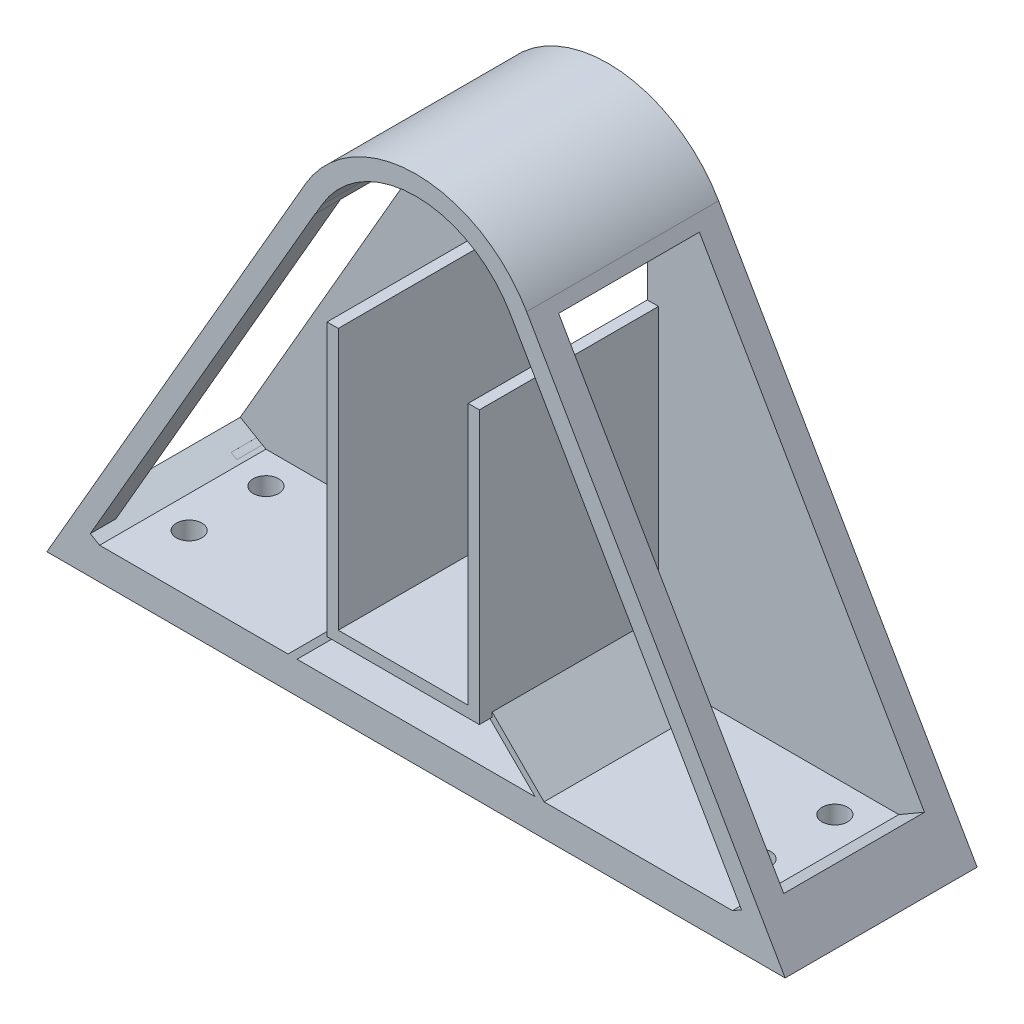
from build123d import *

# Parameters (mm, degrees)
SKETCH2_W                 = 200
SKETCH2_H                 = 200
BOSS_EXTRUDE2_DEPTH       = 60
BOSS_EXTRUDE3_START       = -38
BOSS_EXTRUDE3_DEPTH       = 41
SKETCH5_W                 = 180
SKETCH5_H                 = 180
CUT_EXTRUDE2_DEPTH        = 50
BOSS_EXTRUDE4_START       = -51.2
BOSS_EXTRUDE4_DEPTH       = 30
CUT_EXTRUDE3_DEPTH        = 35
SKETCH9_R                 = 5
CUT_EXTRUDE4_DEPTH        = 10
CUT_EXTRUDE6_DEPTH        = 26
SKETCH11_W                = 120
SKETCH11_H                = 10
CUT_EXTRUDE7_DEPTH        = 26
SKETCH12_W                = 180
SKETCH12_H                = 50
CUT_EXTRUDE8_DEPTH        = 200
SKETCH13_W                = 180
SKETCH13_H                = 50
CUT_EXTRUDE9_DEPTH        = 200
SKETCH15_W                = 19.8
SKETCH15_H                = 40.6
SKETCH15_R                = 4.016151872
CUT_EXTRUDE11_DEPTH       = 10
BOSS_EXTRUDE5_DEPTH       = 26
SKETCH20_W                = 19.8
SKETCH20_H                = 7
CUT_EXTRUDE14_DEPTH       = 8.2
SKETCH22_W                = 22
SKETCH22_H                = 68.38628635
SKETCH22_W_2              = 33
SKETCH22_H_2              = 70.357034464
CUT_EXTRUDE16_DEPTH       = 6
CUT_EXTRUDE17_DEPTH       = 150
SKETCH24_W                = 190
SKETCH24_H                = 55
CUT_EXTRUDE18_DEPTH       = 200
SKETCH41_W                = 200
SKETCH41_H                = 200
SKETCH41_W_2              = 115.381197846
SKETCH41_H_2              = 110.8
CUT_EXTRUDE25_DEPTH       = 100
CUT_EXTRUDE26_DEPTH       = 26
SKETCH43_R                = 85
BOSS_EXTRUDE9_DEPTH       = 5
CUT_EXTRUDE27_DEPTH       = 11
BOSS_EXTRUDE10_DEPTH      = 4
BOSS_EXTRUDE11_DEPTH      = 24
BOSS_EXTRUDE12_DEPTH      = 26
BOSS_EXTRUDE14_DEPTH      = 4
CUT_EXTRUDE29_DEPTH       = 18
CUT_EXTRUDE30_DEPTH       = 2
CUT_EXTRUDE31_DEPTH       = 2
SKETCH55_W                = 19.8
SKETCH55_H                = 2.410200662
BOSS_EXTRUDE16_DEPTH      = 4
SKETCH56_W                = 22
SKETCH56_H                = 70.356823689
CUT_EXTRUDE32_DEPTH       = 4
BOSS_EXTRUDE17_DEPTH      = 26
BOSS_EXTRUDE18_DEPTH      = 26
BOSS_EXTRUDE19_START      = 170
BOSS_EXTRUDE19_DEPTH      = 10
SKETCH60_R                = 2.45
BOSS_EXTRUDE20_DEPTH      = 9
FILLET1_R                 = 0.3
CUT_EXTRUDE33_START       = -1
SKETCH61_R                = 2.45
SKETCH61_R_2              = 2.375
CUT_EXTRUDE33_DEPTH       = 5.2
FILLET2_R                 = 2
BOSS_EXTRUDE21_START      = 140
BOSS_EXTRUDE21_DEPTH      = 10
SKETCH63_R                = 2.45
BOSS_EXTRUDE22_DEPTH      = 9
FILLET3_R                 = 0.3
FILLET4_R                 = 2
CUT_EXTRUDE34_START       = -1
SKETCH64_R                = 2.45
SKETCH64_R_2              = 2.375
CUT_EXTRUDE34_DEPTH       = 5.2
SKETCH67_R                = 95.168377016
SKETCH67_R_2              = 84.75
CUT_EXTRUDE36_DEPTH       = 5
CUT_EXTRUDE37_DEPTH       = 300
CUT_EXTRUDE37_DEPTH_BACK  = 300
SKETCH70_W                = 122.930258841
SKETCH70_H                = 81.480763568
CUT_EXTRUDE39_DEPTH       = 40
F_4_0MM_DOWEL_HOLE1_D     = 4
F_4_0MM_DOWEL_HOLE1_DEPTH = 10
F_4_0MM_DOWEL_HOLE1_TIP   = 1.201721238
SKETCH75_W                = 20.3
SKETCH75_H                = 48.1
CUT_EXTRUDE40_DEPTH       = 50
SKETCH76_W                = 20.3
SKETCH76_H                = 7
CUT_EXTRUDE41_DEPTH       = 8.2
RIB2_REACH                = 214.968


with BuildPart() as part:
    # Sketch2 → Boss-Extrude2 (new body)
    with BuildSketch(Plane(origin=(0, 0, 0), x_dir=(1, 0, 0), z_dir=(0, 1, 0))):
        with Locations((100, 100)):
            Rectangle(SKETCH2_W, SKETCH2_H)
    extrude(amount=BOSS_EXTRUDE2_DEPTH)

    # Sketch3 → Boss-Extrude3 (add)
    with BuildSketch(Plane.XY.offset(BOSS_EXTRUDE3_START)):
        with BuildLine():
            Line((40, 60), (80.980762114, 130.980762114))
            ThreePointArc((80.980762114, 130.980762114), (100, 141.961524227), (119.019237886, 130.980762114))
            Line((119.019237886, 130.980762114), (160, 60))
            Line((160, 60), (40, 60))
        make_face()
    extrude(amount=-BOSS_EXTRUDE3_DEPTH)

    # Sketch5 → Cut-Extrude2 (cut)
    with BuildSketch(Plane.XZ):
        with Locations((100, -100)):
            Rectangle(SKETCH5_W, SKETCH5_H)
    extrude(amount=-CUT_EXTRUDE2_DEPTH, mode=Mode.SUBTRACT)

    # Sketch7 → Boss-Extrude4 (add)
    with BuildSketch(Plane(origin=(0, 0, -200), x_dir=(-1, 0, 0), z_dir=(0, 0, -1)).offset(BOSS_EXTRUDE4_START)):
        with BuildLine():
            Line((-160, 60), (-40, 60))
            Line((-40, 60), (-80.980762114, 130.980762114))
            ThreePointArc((-80.980762114, 130.980762114), (-100, 141.961524227), (-119.019237886, 130.980762114))
            Line((-119.019237886, 130.980762114), (-160, 60))
        make_face()
    extrude(amount=-BOSS_EXTRUDE4_DEPTH)

    # Sketch8 → Cut-Extrude3 (cut)
    with BuildSketch(Plane.XY.offset(-38)):
        with BuildLine():
            Line((48.660254038, 65), (151.339745962, 65))
            Line((151.339745962, 65), (114.689110868, 128.480762114))
            ThreePointArc((114.689110868, 128.480762114), (100, 136.961524227), (85.310889132, 128.480762114))
            Line((85.310889132, 128.480762114), (48.660254038, 65))
        make_face()
    extrude(amount=-CUT_EXTRUDE3_DEPTH, mode=Mode.SUBTRACT)

    # Sketch9 → Cut-Extrude4 (cut)
    with BuildSketch(Plane.XY.offset(-118.8)):
        with BuildLine():
            Line((95, 141.384773704), (95, 105))
            ThreePointArc((95, 105), (100, 110), (105, 105))
            Line((105, 105), (105, 141.384773704))
            ThreePointArc((105, 141.384773704), (100, 141.961524227), (95, 141.384773704))
        make_face()
        with Locations((100, 105)):
            Circle(SKETCH9_R)
    extrude(amount=-CUT_EXTRUDE4_DEPTH, mode=Mode.SUBTRACT)

    # Sketch10 → Cut-Extrude6 (cut)
    with BuildSketch(Plane(origin=(0, 0, -148.8), x_dir=(-1, 0, 0), z_dir=(0, 0, -1))):
        with BuildLine():
            Line((-110, 105), (-110, 133.700120587))
            ThreePointArc((-110, 133.700120587), (-112.617387787, 131.335555987), (-114.689110868, 128.480762114))
            Line((-114.689110868, 128.480762114), (-151.339745962, 65))
            Line((-151.339745962, 65), (-48.660254038, 65))
            Line((-48.660254038, 65), (-85.310889132, 128.480762114))
            ThreePointArc((-85.310889132, 128.480762114), (-87.382612213, 131.335555987), (-90, 133.700120587))
            Line((-90, 133.700120587), (-90, 105))
            ThreePointArc((-90, 105), (-100, 95), (-110, 105))
        make_face()
    extrude(amount=-CUT_EXTRUDE6_DEPTH, mode=Mode.SUBTRACT)

    # Sketch11 → Cut-Extrude7 (cut)
    with BuildSketch(Plane(origin=(0, 60, 0), x_dir=(1, 0, 0), z_dir=(0, 1, 0))):
        with Locations((100, 113.8)):
            Rectangle(SKETCH11_W, SKETCH11_H)
    extrude(amount=-CUT_EXTRUDE7_DEPTH, mode=Mode.SUBTRACT)

    # Sketch12 → Cut-Extrude8 (cut)
    with BuildSketch(Plane(origin=(200, 0, 0), x_dir=(0, 0, -1), z_dir=(1, 0, 0))):
        with Locations((100, 25)):
            Rectangle(SKETCH12_W, SKETCH12_H)
    extrude(amount=-CUT_EXTRUDE8_DEPTH, mode=Mode.SUBTRACT)

    # Sketch13 → Cut-Extrude9 (cut)
    with BuildSketch(Plane.XY):
        with Locations((100, 25)):
            Rectangle(SKETCH13_W, SKETCH13_H)
    extrude(amount=-CUT_EXTRUDE9_DEPTH, mode=Mode.SUBTRACT)

    # Sketch15 → Cut-Extrude11 (cut)
    with BuildSketch(Plane.XY.offset(-73)):
        with Locations((100, 94.7)):
            Rectangle(SKETCH15_W, SKETCH15_H)
        with Locations((100, 105)):
            Circle(SKETCH15_R, mode=Mode.SUBTRACT)
        with Locations((100, 105)):
            Circle(SKETCH15_R)
    extrude(amount=-CUT_EXTRUDE11_DEPTH, mode=Mode.SUBTRACT)

    # Sketch16 → Boss-Extrude5 (add)
    with BuildSketch(Plane.XY.offset(-73)):
        Polygon((88.1, 115), (88.1, 72.4), (111.9, 72.4), (111.9, 115), (109.9, 115), (109.9, 74.4), (90.1, 74.4), (90.1, 115), align=None)
    extrude(amount=BOSS_EXTRUDE5_DEPTH)

    # Sketch20 → Cut-Extrude14 (cut)
    with BuildSketch(Plane(origin=(0, 0, -79), x_dir=(-1, 0, 0), z_dir=(0, 0, -1))):
        with Locations((-100, 118.5)):
            Rectangle(SKETCH20_W, SKETCH20_H)
        with Locations((-100, 70.9)):
            Rectangle(SKETCH20_W, SKETCH20_H)
    extrude(amount=-CUT_EXTRUDE14_DEPTH, mode=Mode.SUBTRACT)

    # Sketch22 → Cut-Extrude16 (cut)
    with BuildSketch(Plane(origin=(4.019237886, -2.320508076, 0), x_dir=(0, 0, 1), z_dir=(-0.8660254037844397, 0.49999999999999806, 0))):
        with Locations((-133.8, 115.729905279)):
            Rectangle(SKETCH22_W, SKETCH22_H)
        with Locations((-58.5, 116.744531222)):
            Rectangle(SKETCH22_W_2, SKETCH22_H_2)
    extrude(amount=-CUT_EXTRUDE16_DEPTH, mode=Mode.SUBTRACT)

    # Sketch23 → Cut-Extrude17 (cut)
    with BuildSketch(Plane.XY.offset(-38)):
        with BuildLine():
            Line((43.464101615, 62), (42.309401077, 60))
            Line((42.309401077, 60), (36.951802896, 60))
            Line((36.951802896, 60), (100, 183.688158135))
            Line((100, 183.688158135), (162.604774917, 60))
            Line((162.604774917, 60), (157.690598923, 60))
            Line((157.690598923, 60), (156.535898385, 62))
            Line((156.535898385, 62), (117.287187079, 129.980762114))
            ThreePointArc((117.287187079, 129.980762114), (100, 139.961524227), (82.712812921, 129.980762114))
            Line((82.712812921, 129.980762114), (43.464101615, 62))
        make_face()
    extrude(amount=-CUT_EXTRUDE17_DEPTH, mode=Mode.SUBTRACT)

    # Sketch24 → Cut-Extrude18 (cut)
    with BuildSketch(Plane(origin=(0, 0, -200), x_dir=(-1, 0, 0), z_dir=(0, 0, -1))):
        with Locations((-100, 27.5)):
            Rectangle(SKETCH24_W, SKETCH24_H)
    extrude(amount=-CUT_EXTRUDE18_DEPTH, mode=Mode.SUBTRACT)

    # Sketch41 → Cut-Extrude25 (cut)
    with BuildSketch(Plane(origin=(0, 60, 0), x_dir=(1, 0, 0), z_dir=(0, 1, 0))):
        with Locations((100, 100)):
            Rectangle(SKETCH41_W, SKETCH41_H)
        with Locations((100, 93.4)):
            Rectangle(SKETCH41_W_2, SKETCH41_H_2, mode=Mode.SUBTRACT)
    extrude(amount=-CUT_EXTRUDE25_DEPTH, mode=Mode.SUBTRACT)


with BuildPart() as cut_extrude25_piece_1:
    # of the separate pieces the step leaves, piece 1, a body of its own (cut_extrude25_pieces)
    add(part.part.solids().sort_by_distance((42.309401077, 55, -108.8))[0])



with BuildPart() as cut_extrude25_piece_2:
    # of the separate pieces the step leaves, piece 2, a body of its own (cut_extrude25_pieces)
    add(part.part.solids().sort_by_distance((42.309401077, 55, -118.8))[0])

    # Sketch38 → Cut-Extrude26 (cut)
    with BuildSketch(Plane(origin=(0, 0, -148.8), x_dir=(-1, 0, 0), z_dir=(0, 0, -1))):
        with BuildLine():
            Line((-110, 133.700120587), (-107, 135.763853262))
            Line((-107, 135.763853262), (-107, 105))
            ThreePointArc((-107, 105), (-100, 98), (-93, 105))
            Line((-93, 105), (-93, 135.763853262))
            Line((-93, 135.763853262), (-90, 133.700120587))
            Line((-90, 133.700120587), (-90, 105))
            ThreePointArc((-90, 105), (-100, 95), (-110, 105))
            Line((-110, 105), (-110, 133.700120587))
        make_face()
    extrude(amount=-CUT_EXTRUDE26_DEPTH, mode=Mode.SUBTRACT)


with BuildPart() as cut_extrude25_piece_1_1:
    add(cut_extrude25_piece_1.part)

    add(cut_extrude25_piece_2.part)  # Boss-Extrude9 merges Cut-Extrude25 piece 2
    # Sketch43 → Boss-Extrude9 (add)
    with BuildSketch(Plane.XZ.offset(-55)):
        with Locations(Location((100, -98.8, 0), (0, 0, 270))):
            Circle(SKETCH43_R)
    extrude(amount=-BOSS_EXTRUDE9_DEPTH)

    # Sketch45 → Cut-Extrude27 (cut)
    with BuildSketch(Plane.XY.offset(-38)):
        with BuildLine():
            Line((42.309401077, 60), (82.712812921, 129.980762114))
            ThreePointArc((82.712812921, 129.980762114), (100, 139.961524227), (117.287187079, 129.980762114))
            Line((117.287187079, 129.980762114), (157.690598923, 60))
            Line((157.690598923, 60), (42.309401077, 60))
        make_face()
        with BuildLine():
            Line((151.339745962, 65), (114.689110868, 128.480762114))
            ThreePointArc((114.689110868, 128.480762114), (100, 136.961524227), (85.310889132, 128.480762114))
            Line((85.310889132, 128.480762114), (48.660254038, 65))
            Line((48.660254038, 65), (151.339745962, 65))
        make_face(mode=Mode.SUBTRACT)
    extrude(amount=-CUT_EXTRUDE27_DEPTH, mode=Mode.SUBTRACT)

    # Sketch46 → Boss-Extrude10 (add)
    with BuildSketch(Plane.XY.offset(-49)):
        Polygon((81.712812921, 128.248711306), (46.534295689, 67.317732125), (49.094273419, 65.839728294), (84.272790651, 126.770707475), align=None)
    extrude(amount=-BOSS_EXTRUDE10_DEPTH)

    # Sketch47 → Boss-Extrude11 (add)
    with BuildSketch(Plane.XY.offset(-73)):
        Polygon((49.1323719, 65.817732125), (50.548725488, 65), (48.660254038, 65), align=None)
    extrude(amount=BOSS_EXTRUDE11_DEPTH)

    # Sketch48 → Boss-Extrude12 (add)
    with BuildSketch(Plane(origin=(0, 0, -122.8), x_dir=(-1, 0, 0), z_dir=(0, 0, -1))):
        Polygon((-49.117745958, 65.792399249), (-50.490221717, 65), (-48.660254038, 65), align=None)
    extrude(amount=BOSS_EXTRUDE12_DEPTH)

    # Sketch49 → Boss-Extrude14 (add)
    with BuildSketch(Plane.XY.offset(-75)):
        Polygon((49.998397304, 65.317732125), (49.094273419, 65.839728294), (84.272790651, 126.770707475), (85.176914536, 126.248711306), align=None)
    extrude(amount=BOSS_EXTRUDE14_DEPTH)

    # Sketch52 → Cut-Extrude29 (cut)
    with BuildSketch(Plane(origin=(0, 0, -148.8), x_dir=(-1, 0, 0), z_dir=(0, 0, -1))):
        with BuildLine():
            Line((-93, 135.763853262), (-93, 105))
            ThreePointArc((-93, 105), (-100, 98), (-107, 105))
            Line((-107, 105), (-107, 135.763853262))
            ThreePointArc((-107, 135.763853262), (-100, 137.248161341), (-93, 135.763853262))
        make_face()
    extrude(amount=-CUT_EXTRUDE29_DEPTH, mode=Mode.SUBTRACT)

    # Sketch53 → Cut-Extrude30 (cut)
    with BuildSketch(Plane.XY.offset(-71)):
        Polygon((85.176914536, 126.248711306), (84.272790651, 126.770707475), (49.090707581, 65.833552081), (49.994831466, 65.311555913), align=None)
    extrude(amount=-CUT_EXTRUDE30_DEPTH, mode=Mode.SUBTRACT)

    # Sketch54 → Cut-Extrude31 (cut)
    with BuildSketch(Plane.XY.offset(-73)):
        with BuildLine():
            Line((49.090707581, 65.833552081), (49.994831466, 65.311555913))
            Line((49.994831466, 65.311555913), (49.998397304, 65.317732125))
            Line((49.998397304, 65.317732125), (50.548725488, 65))
            Line((50.548725488, 65), (151.339745962, 65))
            Line((151.339745962, 65), (114.689110868, 128.480762114))
            ThreePointArc((114.689110868, 128.480762114), (100, 136.961524227), (85.310889132, 128.480762114))
            Line((85.310889132, 128.480762114), (84.310889132, 126.748711306))
            Line((84.310889132, 126.748711306), (84.272790651, 126.770707475))
            Line((84.272790651, 126.770707475), (49.094273419, 65.839728294))
            Line((49.094273419, 65.839728294), (49.090707581, 65.833552081))
        make_face()
        Polygon((90.1, 122), (109.9, 122), (109.9, 115), (111.9, 115), (111.9, 72.4), (109.9, 72.4), (109.9, 67.4), (90.1, 67.4), (90.1, 72.4), (88.1, 72.4), (88.1, 115), (90.1, 115), align=None, mode=Mode.SUBTRACT)
    extrude(amount=-CUT_EXTRUDE31_DEPTH, mode=Mode.SUBTRACT)

    # Sketch55 → Boss-Extrude16 (add)
    with BuildSketch(Plane.XY.offset(-75)):
        with Locations((100, 66.194899669)):
            Rectangle(SKETCH55_W, SKETCH55_H)
    extrude(amount=BOSS_EXTRUDE16_DEPTH)

    # Sketch56 → Cut-Extrude32 (cut)
    with BuildSketch(Plane(origin=(144.248711306, 83.282032303, 0), x_dir=(0, 0, -1), z_dir=(0.8660254037844362, 0.5000000000000044, 0))):
        with Locations((64, 16.744636609)):
            Rectangle(SKETCH56_W, SKETCH56_H)
        with Locations((133.8, 16.744636609)):
            Rectangle(SKETCH56_W, SKETCH56_H)
    extrude(amount=-CUT_EXTRUDE32_DEPTH, mode=Mode.SUBTRACT)

    # Sketch57 → Boss-Extrude17 (add)
    with BuildSketch(Plane.XY.offset(-75)):
        Polygon((150.867522712, 65.817914662), (149.450852961, 65), (151.339745962, 65), align=None)
    extrude(amount=BOSS_EXTRUDE17_DEPTH)

    # Sketch58 → Boss-Extrude18 (add)
    with BuildSketch(Plane(origin=(0, 0, -122.8), x_dir=(-1, 0, 0), z_dir=(0, 0, -1))):
        Polygon((-150.867522712, 65.817914662), (-151.339745962, 65), (-149.450852961, 65), align=None)
    extrude(amount=BOSS_EXTRUDE18_DEPTH)

    # Sketch59 → Boss-Extrude19 (add)
    with BuildSketch(Plane(origin=(0, 0, 0), x_dir=(0, 0, -1), z_dir=(1, 0, 0)).offset(BOSS_EXTRUDE19_START)):
        with BuildLine():
            Line((81.4, 60), (94.15, 72.75))
            ThreePointArc((94.15, 72.75), (98.9, 74.717514421), (103.65, 72.75))
            Line((103.65, 72.75), (116.4, 60))
            Line((116.4, 60), (81.4, 60))
        make_face()
        with BuildLine():
            Line((81.4, 55), (116.4, 55))
            Line((116.4, 55), (103.65, 42.25))
            ThreePointArc((103.65, 42.25), (98.9, 40.282485579), (94.15, 42.25))
            Line((94.15, 42.25), (81.4, 55))
        make_face()
    extrude(amount=BOSS_EXTRUDE19_DEPTH)

    # Sketch60 → Boss-Extrude20 (add)
    with BuildSketch(Plane(origin=(180, 0, 0), x_dir=(0, 0, -1), z_dir=(1, 0, 0))):
        with Locations(Location((98.9, 70, 0), (0, 0, 180))):
            Circle(SKETCH60_R)
        with Locations(Location((98.9, 45, 0), (0, 0, 180))):
            Circle(SKETCH60_R)
    extrude(amount=BOSS_EXTRUDE20_DEPTH)

    # Fillet1
    fillet1_edges = [cut_extrude25_piece_1_1.edges().sort_by_distance(p)[0] for p in [
        (189, 70, -101.35),
        (189, 45, -101.35),
    ]]
    fillet(fillet1_edges, radius=FILLET1_R)

    # Sketch61 → Cut-Extrude33 (cut)
    with BuildSketch(Plane(origin=(189, 0, 0), x_dir=(0, 0, -1), z_dir=(1, 0, 0)).offset(CUT_EXTRUDE33_START)):
        with Locations(Location((98.9, 70, 0), (0, 0, 180))):
            Circle(SKETCH61_R)
        with Locations((98.9, 70)):
            Circle(SKETCH61_R_2, mode=Mode.SUBTRACT)
        with Locations(Location((98.9, 45, 0), (0, 0, 180))):
            Circle(SKETCH61_R)
        with Locations(Location((98.9, 45, 0), (0, 0, 180))):
            Circle(SKETCH61_R_2, mode=Mode.SUBTRACT)
    extrude(amount=-CUT_EXTRUDE33_DEPTH, mode=Mode.SUBTRACT)

    # Fillet2
    fillet2_edges = [cut_extrude25_piece_1_1.edges().sort_by_distance(p)[0] for p in [
        (180, 70, -101.35),
        (180, 45, -101.35),
    ]]
    fillet(fillet2_edges, radius=FILLET2_R)

    # Sketch62 → Boss-Extrude21 (add)
    with BuildSketch(Plane.ZY.offset(-170).offset(BOSS_EXTRUDE21_START)):
        with BuildLine():
            Line((-81.4, 55), (-94.15, 42.25))
            ThreePointArc((-94.15, 42.25), (-98.9, 40.282485579), (-103.65, 42.25))
            Line((-103.65, 42.25), (-116.4, 55))
            Line((-116.4, 55), (-81.4, 55))
        make_face()
    extrude(amount=BOSS_EXTRUDE21_DEPTH)

    # Sketch63 → Boss-Extrude22 (add)
    with BuildSketch(Plane.ZY.offset(-20)):
        with Locations((-98.9, 45)):
            Circle(SKETCH63_R)
    extrude(amount=BOSS_EXTRUDE22_DEPTH)

    # Fillet3
    fillet3_edges = [cut_extrude25_piece_1_1.edges().sort_by_distance(p)[0] for p in [
        (11, 45, -101.35),
    ]]
    fillet(fillet3_edges, radius=FILLET3_R)

    # Fillet4
    fillet4_edges = [cut_extrude25_piece_1_1.edges().sort_by_distance(p)[0] for p in [
        (20, 45, -101.35),
    ]]
    fillet(fillet4_edges, radius=FILLET4_R)

    # Sketch64 → Cut-Extrude34 (cut)
    with BuildSketch(Plane.ZY.offset(-11).offset(CUT_EXTRUDE34_START)):
        with Locations((-98.9, 45)):
            Circle(SKETCH64_R)
        with Locations((-98.9, 45)):
            Circle(SKETCH64_R_2, mode=Mode.SUBTRACT)
    extrude(amount=-CUT_EXTRUDE34_DEPTH, mode=Mode.SUBTRACT)

    # Sketch67 → Cut-Extrude36 (cut)
    with BuildSketch(Plane(origin=(0, 60, 0), x_dir=(1, 0, 0), z_dir=(0, 1, 0))):
        with Locations((100, 98.8)):
            Circle(SKETCH67_R)
        with Locations(Location((100, 98.8, 0), (0, 0, 270))):
            Circle(SKETCH67_R_2, mode=Mode.SUBTRACT)
    extrude(amount=-CUT_EXTRUDE36_DEPTH, mode=Mode.SUBTRACT)

    # Sketch69 → Cut-Extrude37 (cut, two sides)
    with BuildSketch(Plane.XY.offset(-49)) as cut_extrude37_sk:
        Polygon((215.911879912, 60), (228.126422398, 60), (228.126422398, 82.352259546), (166.655319243, 82.352259546), (166.655319243, 60), (-1.892498908, 60), (-1.892498908, 17.905538861), (184.75, 17.905538861), (184.75, 13.056821612), (215.911879912, 13.056821612), align=None)
    extrude(amount=CUT_EXTRUDE37_DEPTH, mode=Mode.SUBTRACT)
    extrude(cut_extrude37_sk.sketch, amount=-CUT_EXTRUDE37_DEPTH_BACK, mode=Mode.SUBTRACT)


with BuildPart() as cut_extrude37_piece_1:
    # of the separate pieces the step leaves, piece 1, a body of its own (cut_extrude37_pieces)
    add(cut_extrude25_piece_1_1.part.solids().sort_by_distance((117.287187079, 129.980762114, -49))[0])

    # Ø4.0mm Dowel Hole1
    with Locations(Plane(origin=(0, 65, 0), x_dir=(1, 0, 0), z_dir=(0, 1, 0))):
        with Locations((55.548725488, 70), (55.548725488, 58), (144.450852961, 70), (144.450852961, 58)):
            Hole(F_4_0MM_DOWEL_HOLE1_D / 2, depth=F_4_0MM_DOWEL_HOLE1_DEPTH)
            with Locations((0, 0, -(F_4_0MM_DOWEL_HOLE1_DEPTH + F_4_0MM_DOWEL_HOLE1_TIP / 2))):  # 118° drill point
                Cone(0, F_4_0MM_DOWEL_HOLE1_D / 2, F_4_0MM_DOWEL_HOLE1_TIP, mode=Mode.SUBTRACT)

    # Sketch75 → Cut-Extrude40 (cut)
    with BuildSketch(Plane(origin=(0, 0, -79), x_dir=(-1, 0, 0), z_dir=(0, 0, -1))):
        with Locations((-100, 98.2)):
            Rectangle(SKETCH75_W, SKETCH75_H)
    extrude(amount=-CUT_EXTRUDE40_DEPTH, mode=Mode.SUBTRACT)

    # Sketch76 → Cut-Extrude41 (cut)
    with BuildSketch(Plane(origin=(0, 0, -79), x_dir=(-1, 0, 0), z_dir=(0, 0, -1))):
        with Locations((-100, 70.65)):
            Rectangle(SKETCH76_W, SKETCH76_H)
    extrude(amount=-CUT_EXTRUDE41_DEPTH, mode=Mode.SUBTRACT)

    # Sketch78 walls → Rib2 (add, up to next)
    with BuildSketch(Plane.XY.offset(-49), mode=Mode.PRIVATE) as rib2_sk1:
        Polygon((239.044976209, 224.05208299), (-70.95208299, -85.944976209), (-70.244976209, -86.65208299), (239.75208299, 223.344976209), align=None)
    rib2_tool1 = extrude(rib2_sk1.sketch, amount=-RIB2_REACH, mode=Mode.PRIVATE) - cut_extrude37_piece_1.part
    # Sketch78 walls → Rib2 (add, up to next)
    with BuildSketch(Plane.XY.offset(-49), mode=Mode.PRIVATE) as rib2_sk2:
        Polygon((-39.75208299, 223.344976209), (270.244976209, -86.65208299), (270.95208299, -85.944976209), (-39.044976209, 224.05208299), align=None)
    rib2_tool2 = extrude(rib2_sk2.sketch, amount=-RIB2_REACH, mode=Mode.PRIVATE) - cut_extrude37_piece_1.part
    add(rib2_tool1.solids().sort_by_distance((84.4, 68.7, -49))[0])
    add(rib2_tool2.solids().sort_by_distance((115.6, 68.7, -49))[0])


with BuildPart() as cut_extrude37_piece_2:
    # of the separate pieces the step leaves, piece 2, a body of its own (cut_extrude37_pieces)
    add(cut_extrude25_piece_1_1.part.solids().sort_by_distance((42.309401077, 60, -118.8))[0])

    # Sketch70 → Cut-Extrude39 (cut)
    with BuildSketch(Plane(origin=(0, 0, -148.8), x_dir=(-1, 0, 0), z_dir=(0, 0, -1))):
        with Locations((-96.225469503, 100.740381784)):
            Rectangle(SKETCH70_W, SKETCH70_H)
    extrude(amount=-CUT_EXTRUDE39_DEPTH, mode=Mode.SUBTRACT)


solid = cut_extrude37_piece_1.part
